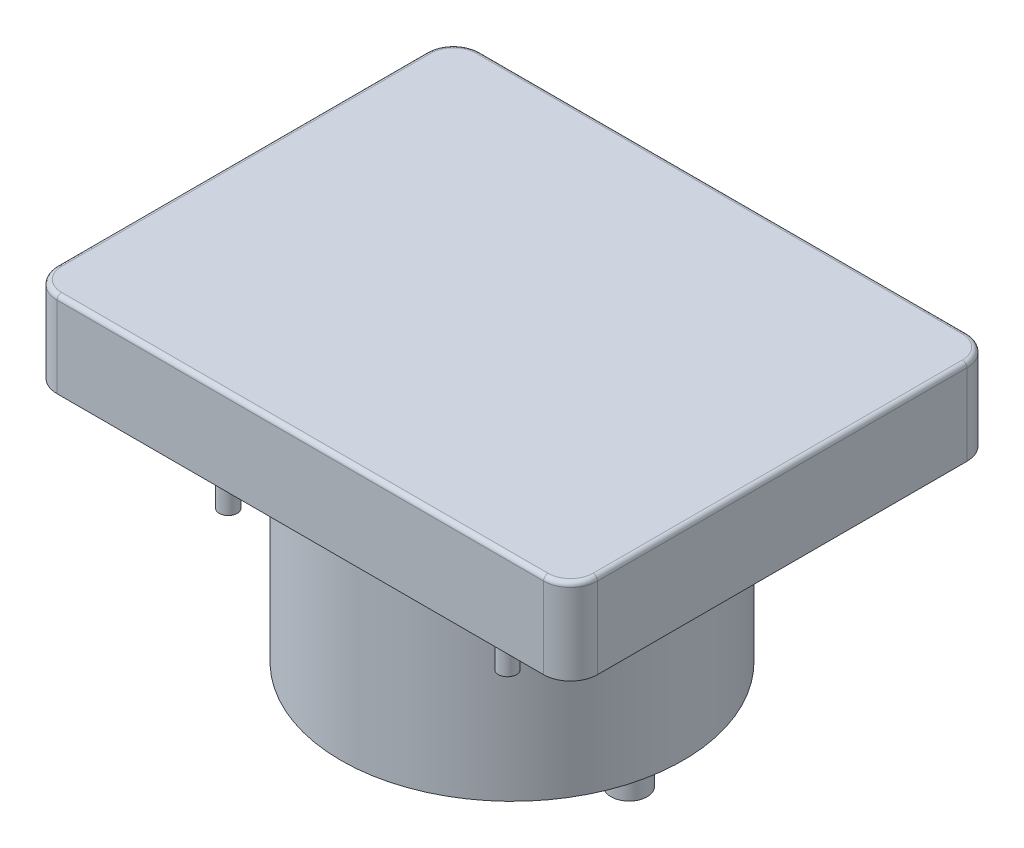
from build123d import *

# Parameters (mm, degrees)
SKETCH1_W           = 60
SKETCH1_H           = 47
BOSS_EXTRUDE1_DEPTH = 9.5
SKETCH1_3_R         = 1
BOSS_EXTRUDE2_DEPTH = 9
SKETCH1_4_R         = 2
BOSS_EXTRUDE3_DEPTH = 29.5
SKETCH1_5_R         = 19
BOSS_EXTRUDE4_DEPTH = 24
FILLET1_R           = 3
FILLET2_R           = 0.5


with BuildPart() as part:
    # Sketch1 → Boss-Extrude1 (new body)
    with BuildSketch(Plane(origin=(0, 0, 0), x_dir=(1, 0, 0), z_dir=(0, 1, 0))):
        Rectangle(SKETCH1_W, SKETCH1_H)
    extrude(amount=BOSS_EXTRUDE1_DEPTH)

    # Sketch1_3 → Boss-Extrude2 (add)
    with BuildSketch(Plane(origin=(0, 0, 0), x_dir=(1, 0, 0), z_dir=(0, 1, 0))):
        with Locations((-15.5, 16)):
            Circle(SKETCH1_3_R)
        with Locations((15.5, 16)):
            Circle(SKETCH1_3_R)
        with Locations((15.5, -16)):
            Circle(SKETCH1_3_R)
        with Locations((-15.5, -16)):
            Circle(SKETCH1_3_R)
    extrude(amount=-BOSS_EXTRUDE2_DEPTH)

    # Sketch1_4 → Boss-Extrude3 (add)
    with BuildSketch(Plane(origin=(0, 0, 0), x_dir=(1, 0, 0), z_dir=(0, 1, 0))):
        with Locations((13, 0)):
            Circle(SKETCH1_4_R)
        with Locations((-13, 0)):
            Circle(SKETCH1_4_R)
    extrude(amount=-BOSS_EXTRUDE3_DEPTH)

    # Sketch1_5 → Boss-Extrude4 (add)
    with BuildSketch(Plane(origin=(0, 0, 0), x_dir=(1, 0, 0), z_dir=(0, 1, 0))):
        Circle(SKETCH1_5_R)
    extrude(amount=-BOSS_EXTRUDE4_DEPTH)

    # Fillet1
    fillet1_edges = [part.edges().sort_by_distance(p)[0] for p in [
        (-30, 4.75, 23.5),
        (30, 4.75, 23.5),
        (-30, 4.75, -23.5),
        (30, 4.75, -23.5),
    ]]
    fillet(fillet1_edges, radius=FILLET1_R)

    # Fillet2
    fillet2_edges = [part.edges().sort_by_distance(p)[0] for p in [
        (29.121320344, 9.5, 22.621320344),
        (0, 9.5, 23.5),
        (-29.121320344, 9.5, 22.621320344),
        (-30, 9.5, 0),
        (-29.121320344, 9.5, -22.621320344),
        (0, 9.5, -23.5),
        (29.121320344, 9.5, -22.621320344),
        (30, 9.5, 0),
    ]]
    fillet(fillet2_edges, radius=FILLET2_R)


solid = part.part
